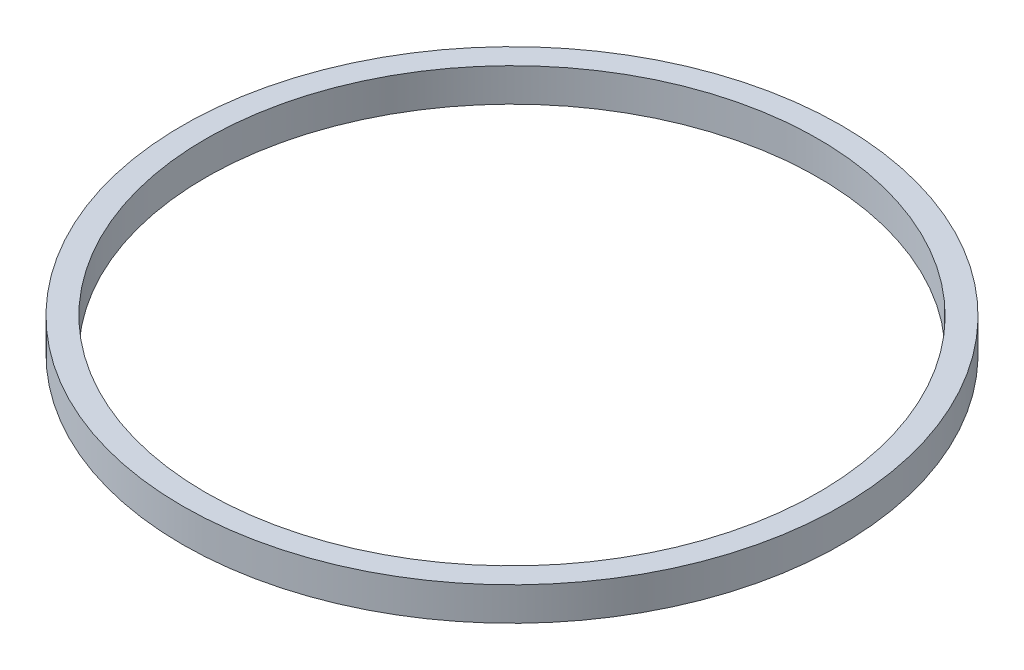
from build123d import *

# Parameters (mm, degrees)
SKETCH1_R           = 1079.5
SKETCH1_R_2         = 1003.3
BOSS_EXTRUDE1_DEPTH = 109.22


with BuildPart() as part:
    # Sketch1 → Boss-Extrude1 (new body)
    with BuildSketch(Plane(origin=(0, 0, 0), x_dir=(1, 0, 0), z_dir=(0, 1, 0))):
        Circle(SKETCH1_R)
        Circle(SKETCH1_R_2, mode=Mode.SUBTRACT)
    extrude(amount=BOSS_EXTRUDE1_DEPTH)


solid = part.part
